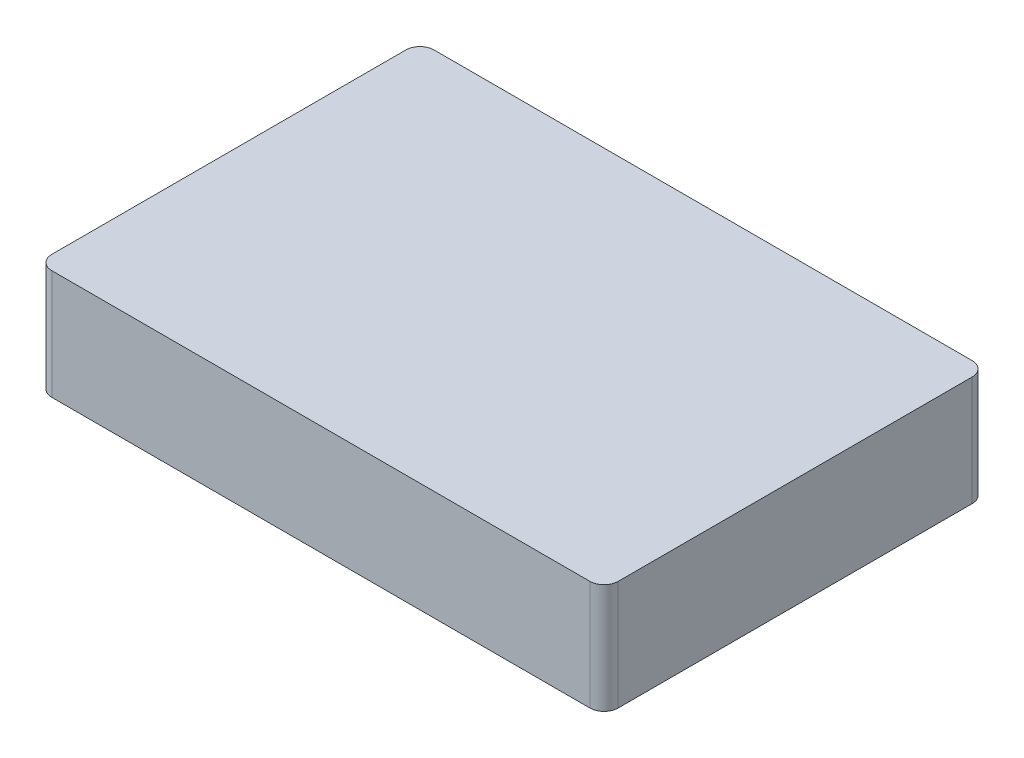
from build123d import *

# Parameters (mm, degrees)
SKETCH1_W           = 80
SKETCH1_H           = 54
BOSS_EXTRUDE2_DEPTH = 15.5
FILLET1_R           = 2


with BuildPart() as part:
    # Sketch1 → Boss-Extrude2 (new body)
    with BuildSketch(Plane(origin=(0, 0, 0), x_dir=(1, 0, 0), z_dir=(0, 1, 0))):
        with Locations((40, 27)):
            Rectangle(SKETCH1_W, SKETCH1_H)
    extrude(amount=BOSS_EXTRUDE2_DEPTH)

    # Fillet1
    fillet1_edges = [part.edges().sort_by_distance(p)[0] for p in [
        (0, 7.75, -54),
        (80, 7.75, -54),
        (80, 7.75, 0),
        (0, 7.75, 0),
    ]]
    fillet(fillet1_edges, radius=FILLET1_R)


solid = part.part
